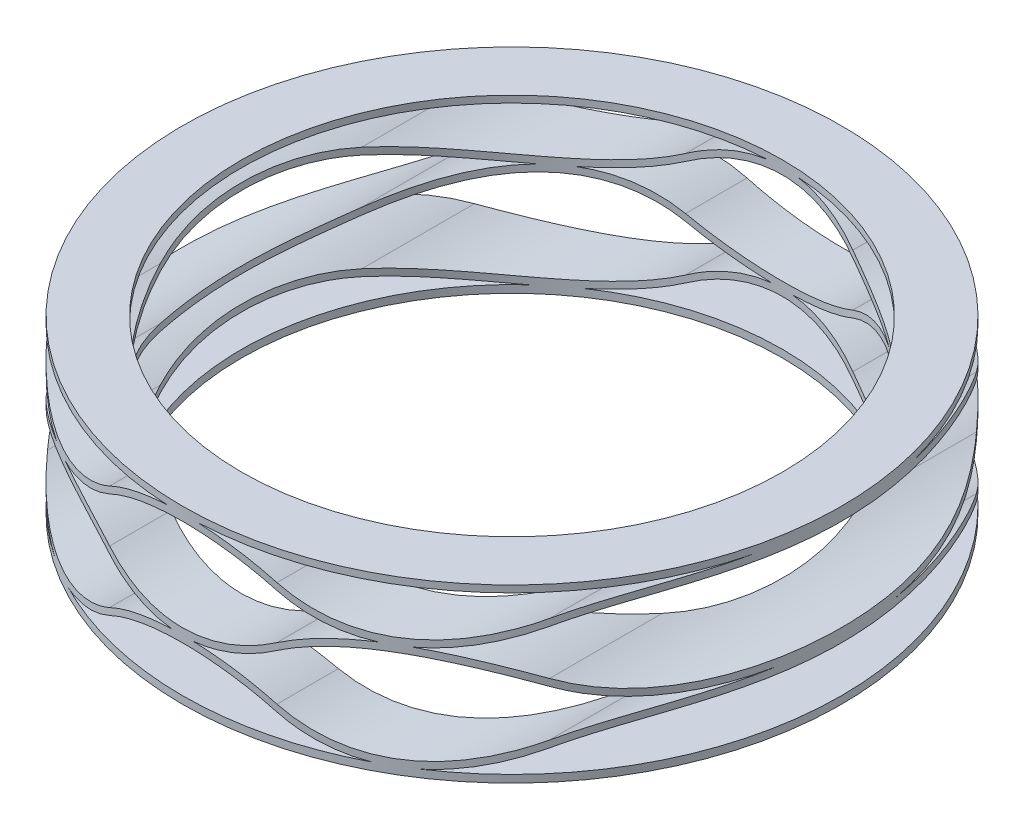
from build123d import *

# Parameters (mm, degrees)
SKETCH1_W           = 29.718
SKETCH1_H           = 29.718
EXTRUDE1_DEPTH      = 0.2794
EXTRUDE2_DEPTH      = 14.859
EXTRUDE2_DEPTH_BACK = 14.859
EXTRUDE3_DEPTH      = 14.859
EXTRUDE3_DEPTH_BACK = 14.859
EXTRUDE4_DEPTH      = 14.859
EXTRUDE4_DEPTH_BACK = 14.859
SKETCH5_W           = 29.718
SKETCH5_H           = 29.718
EXTRUDE5_DEPTH      = 0.254
SKETCH6_W           = 49.53
SKETCH6_H           = 49.53
SKETCH6_R           = 12.192
EXTRUDE6_DEPTH      = 6.35
SKETCH7_R           = 10.0076
EXTRUDE7_DEPTH      = 6.35


with BuildPart() as part:
    # Sketch1 → Extrude1 (new body)
    with BuildSketch(Plane(origin=(0, 0, 0), x_dir=(-1, 0, 0), z_dir=(0, 1, 0))):
        Rectangle(SKETCH1_W, SKETCH1_H)
    extrude(amount=EXTRUDE1_DEPTH)

    # Sketch2 → Extrude2 (add, two sides: drawn at the far end of the back side and taken through both)
    with BuildSketch(Plane.XY.offset(-EXTRUDE2_DEPTH_BACK)):
        with BuildLine():
            Line((15.478125, 1.100666667), (15.478125, 1.354666667))
            ThreePointArc((15.478125, 1.354666667), (12.3825, 2.226733333), (9.286875, 1.354666667))
            ThreePointArc((9.286875, 1.354666667), (6.19125, 0.508), (3.095625, 1.354666667))
            ThreePointArc((3.095625, 1.354666667), (0, 2.226733333), (-3.095625, 1.354666667))
            ThreePointArc((-3.095625, 1.354666667), (-6.19125, 0.508), (-9.286875, 1.354666667))
            ThreePointArc((-9.286875, 1.354666667), (-12.3825, 2.226733333), (-15.478125, 1.354666667))
            Line((-15.478125, 1.354666667), (-15.478125, 1.100666667))
            ThreePointArc((-15.478125, 1.100666667), (-12.3825, 1.972733333), (-9.286875, 1.100666667))
            ThreePointArc((-9.286875, 1.100666667), (-6.19125, 0.254), (-3.095625, 1.100666667))
            ThreePointArc((-3.095625, 1.100666667), (0, 1.972733333), (3.095625, 1.100666667))
            ThreePointArc((3.095625, 1.100666667), (6.19125, 0.254), (9.286875, 1.100666667))
            ThreePointArc((9.286875, 1.100666667), (12.3825, 1.972733333), (15.478125, 1.100666667))
        make_face()
    extrude(amount=EXTRUDE2_DEPTH + EXTRUDE2_DEPTH_BACK)

    # Sketch3 → Extrude3 (add, two sides: drawn at the far end of the back side and taken through both)
    with BuildSketch(Plane.XY.offset(-EXTRUDE3_DEPTH_BACK)):
        with BuildLine():
            Line((-15.478125, 3.3274), (-15.478125, 3.0734))
            ThreePointArc((-15.478125, 3.0734), (-12.3825, 2.201333333), (-9.286875, 3.0734))
            ThreePointArc((-9.286875, 3.0734), (-6.19125, 3.920066667), (-3.095625, 3.0734))
            ThreePointArc((-3.095625, 3.0734), (0, 2.201333333), (3.095625, 3.0734))
            ThreePointArc((3.095625, 3.0734), (6.19125, 3.920066667), (9.286875, 3.0734))
            ThreePointArc((9.286875, 3.0734), (12.3825, 2.201333333), (15.478125, 3.0734))
            Line((15.478125, 3.0734), (15.478125, 3.3274))
            ThreePointArc((15.478125, 3.3274), (12.3825, 2.455333333), (9.286875, 3.3274))
            ThreePointArc((9.286875, 3.3274), (6.19125, 4.174066667), (3.095625, 3.3274))
            ThreePointArc((3.095625, 3.3274), (0, 2.455333333), (-3.095625, 3.3274))
            ThreePointArc((-3.095625, 3.3274), (-6.19125, 4.174066667), (-9.286875, 3.3274))
            ThreePointArc((-9.286875, 3.3274), (-12.3825, 2.455333333), (-15.478125, 3.3274))
        make_face()
    extrude(amount=EXTRUDE3_DEPTH + EXTRUDE3_DEPTH_BACK)

    # Sketch4 → Extrude4 (add, two sides: drawn at the far end of the back side and taken through both)
    with BuildSketch(Plane.XY.offset(-EXTRUDE4_DEPTH_BACK)):
        with BuildLine():
            Line((15.478125, 4.995333333), (15.478125, 5.249333333))
            ThreePointArc((15.478125, 5.249333333), (12.3825, 6.1214), (9.286875, 5.249333333))
            ThreePointArc((9.286875, 5.249333333), (6.19125, 4.402666667), (3.095625, 5.249333333))
            ThreePointArc((3.095625, 5.249333333), (0, 6.1214), (-3.095625, 5.249333333))
            ThreePointArc((-3.095625, 5.249333333), (-6.19125, 4.402666667), (-9.286875, 5.249333333))
            ThreePointArc((-9.286875, 5.249333333), (-12.3825, 6.1214), (-15.478125, 5.249333333))
            Line((-15.478125, 5.249333333), (-15.478125, 4.995333333))
            ThreePointArc((-15.478125, 4.995333333), (-12.3825, 5.8674), (-9.286875, 4.995333333))
            ThreePointArc((-9.286875, 4.995333333), (-6.19125, 4.148666667), (-3.095625, 4.995333333))
            ThreePointArc((-3.095625, 4.995333333), (0, 5.8674), (3.095625, 4.995333333))
            ThreePointArc((3.095625, 4.995333333), (6.19125, 4.148666667), (9.286875, 4.995333333))
            ThreePointArc((9.286875, 4.995333333), (12.3825, 5.8674), (15.478125, 4.995333333))
        make_face()
    extrude(amount=EXTRUDE4_DEPTH + EXTRUDE4_DEPTH_BACK)

    # Sketch5 → Extrude5 (add)
    with BuildSketch(Plane(origin=(0, 6.096, 0), x_dir=(-1, 0, 0), z_dir=(0, 1, 0))):
        Rectangle(SKETCH5_W, SKETCH5_H)
    extrude(amount=EXTRUDE5_DEPTH)

    # Sketch6 → Extrude6 (cut)
    with BuildSketch(Plane(origin=(0, 0, 0), x_dir=(-1, 0, 0), z_dir=(0, 1, 0))):
        Rectangle(SKETCH6_W, SKETCH6_H)
        Circle(SKETCH6_R, mode=Mode.SUBTRACT)
    extrude(amount=EXTRUDE6_DEPTH, mode=Mode.SUBTRACT)

    # Sketch7 → Extrude7 (cut)
    with BuildSketch(Plane(origin=(0, 0, 0), x_dir=(-1, 0, 0), z_dir=(0, 1, 0))):
        Circle(SKETCH7_R)
    extrude(amount=EXTRUDE7_DEPTH, mode=Mode.SUBTRACT)


solid = part.part
